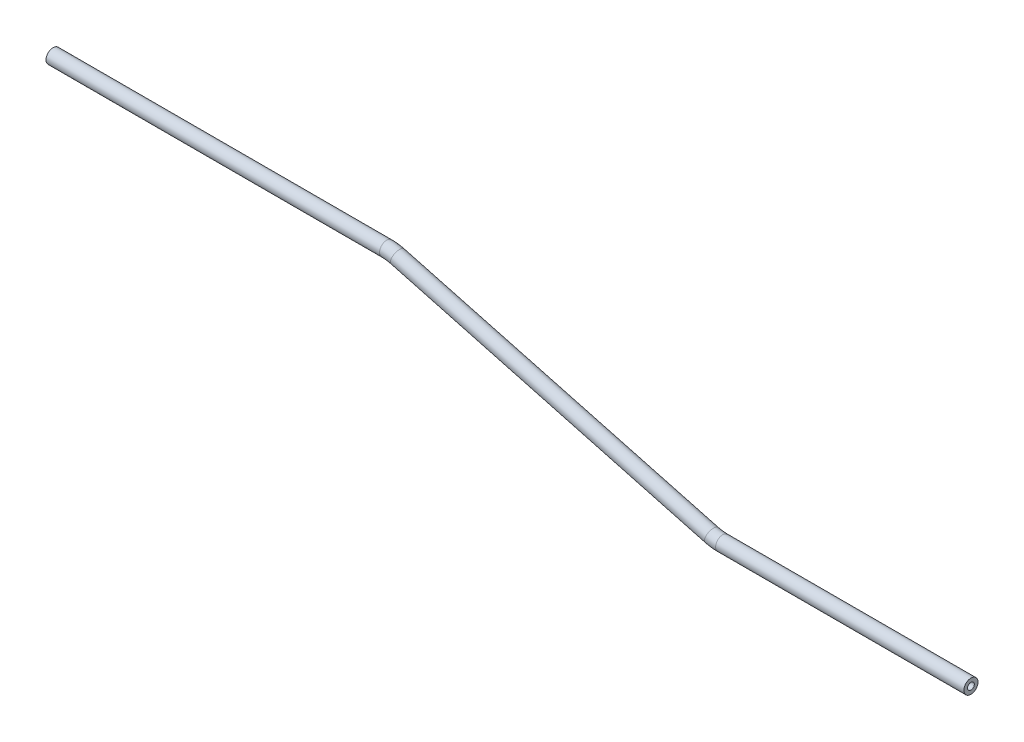
from build123d import *

# Parameters (mm, degrees)
SKETCH2_R   = 3.175
SKETCH2_R_2 = 1.524


with BuildPart() as part:
    # Sweep1: sweep along a path in Sketch1
    with BuildLine(Plane.XY) as sweep1_path:
        Line((-134.955757404, 7.163758353), (14.936262517, 7.163758353))
        ThreePointArc((14.936262517, 7.163758353), (17.422786479, 7.000782962), (19.866765326, 6.514645344))
        Line((19.866765326, 6.514645344), (161.004543444, -31.303108324))
        ThreePointArc((161.004543444, -31.303108324), (163.448522292, -31.789245943), (165.935046254, -31.952221333))
        Line((165.935046254, -31.952221333), (277.481143375, -31.952221333))
    # Sketch2 → Sweep1 (sweep)
    with BuildSketch(Plane(origin=(-134.955757404, 7.163758353, 0), x_dir=(0, 0, -1), z_dir=(1, 0, 0))):
        Circle(SKETCH2_R)
        Circle(SKETCH2_R_2, mode=Mode.SUBTRACT)
    sweep(path=sweep1_path.line)


solid = part.part
